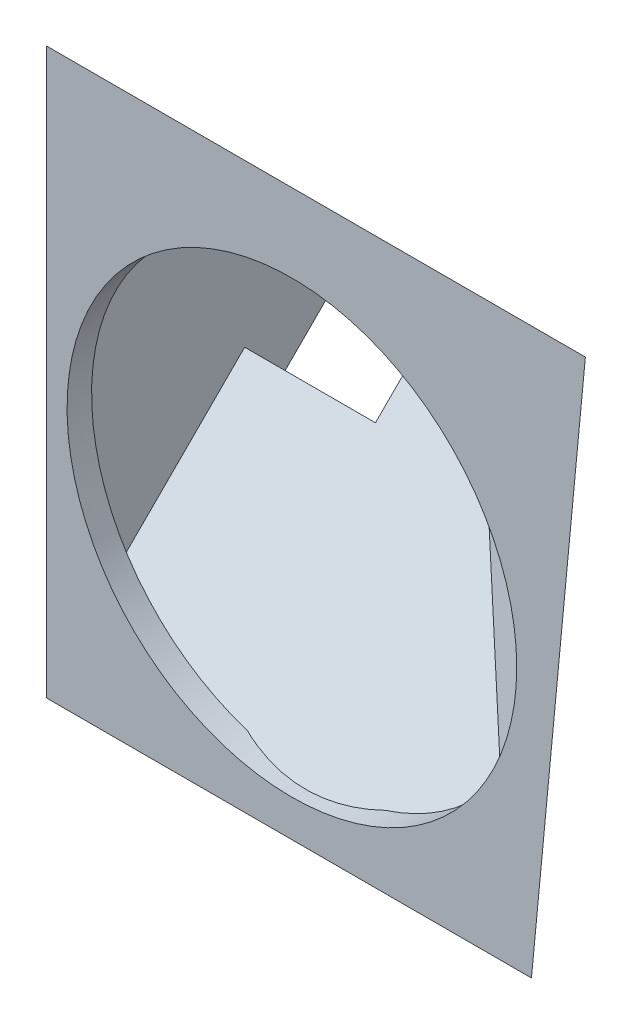
from build123d import *

# Parameters (mm, degrees)
SKETCH1_W            = 60
SKETCH1_H            = 60
SKETCH1_R            = 27.5
BOSS_EXTRUDE2_DEPTH  = 2
BOSS_EXTRUDE3_DEPTH  = 1
BOSS_EXTRUDE4_DEPTH  = 59
BOSS_EXTRUDE5_DEPTH  = 20
SKETCH6_W            = 4
SKETCH6_H            = 14.848240743
CUT_EXTRUDE1_DEPTH   = 20
BOSS_EXTRUDE6_DEPTH  = 2
SKETCH9_W            = 21
SKETCH9_H            = 33.426406871
BOSS_EXTRUDE8_DEPTH  = 2
SKETCH11_W           = 57.719066806
SKETCH11_H           = 59.906444101
BOSS_EXTRUDE9_DEPTH  = 1.5
CUT_EXTRUDE3_DEPTH   = 44.570078861
BOSS_EXTRUDE10_REACH = 41.922
CUT_EXTRUDE4_DEPTH   = 26.5
SKETCH15_W           = 98.795654727
SKETCH15_H           = 69.251879537
CUT_EXTRUDE5_DEPTH   = 59.5
SKETCH16_R           = 67.668555037
CUT_EXTRUDE6_DEPTH   = 1093.5
SKETCH17_R           = 80.414803425
CUT_EXTRUDE7_DEPTH   = 212.5
SKETCH18_W           = 81.243812254
SKETCH18_H           = 75.888975698
SKETCH18_R           = 27.5
BOSS_EXTRUDE12_DEPTH = 3
BOSS_EXTRUDE13_DEPTH = 2
SKETCH20_R           = 82.636183776
CUT_EXTRUDE8_DEPTH   = 100
SKETCH21_R           = 85.046347758
CUT_EXTRUDE9_DEPTH   = 22
SKETCH23_R           = 93.159906211
CUT_EXTRUDE11_DEPTH  = 94
SKETCH24_R           = 86.281354965
CUT_EXTRUDE12_DEPTH  = 48
SKETCH25_R           = 66.198443884
CUT_EXTRUDE13_DEPTH  = 170
BOSS_EXTRUDE14_DEPTH = 2
SKETCH27_W           = 18.5
SKETCH27_H           = 15.5
SKETCH27_W_2         = 16
SKETCH27_H_2         = 12
BOSS_EXTRUDE15_DEPTH = 5


with BuildPart() as part:
    # Sketch1 → Boss-Extrude2 (new body)
    with BuildSketch(Plane.XY):
        with Locations((28, 28)):
            Rectangle(SKETCH1_W, SKETCH1_H)
        with Locations((28, 28)):
            Circle(SKETCH1_R, mode=Mode.SUBTRACT)
    extrude(amount=BOSS_EXTRUDE2_DEPTH)

    # Sketch2 → Boss-Extrude3 (add)
    with BuildSketch(Plane.ZY.offset(2)):
        Polygon((2, 58), (-1.535533906, 61.535533906), (-32.535533906, 30.535533906), (0, -2), (0, 58), align=None)
    extrude(amount=-BOSS_EXTRUDE3_DEPTH)

    # Sketch3 → Boss-Extrude4 (add)
    with BuildSketch(Plane(origin=(-1, 0, 0), x_dir=(0, 0, -1), z_dir=(1, 0, 0))):
        Polygon((0, 58), (2.535533906, 60.535533906), (1.535533906, 61.535533906), (-2, 58), align=None)
    extrude(amount=BOSS_EXTRUDE4_DEPTH)

    # Sketch5 → Boss-Extrude5 (add)
    with BuildSketch(Plane(origin=(-1, 0, 0), x_dir=(0, 0, -1), z_dir=(1, 0, 0))):
        Polygon((2.535533906, 60.535533906), (32.535533906, 30.535533906), (31.121320344, 29.121320344), (1.121320344, 59.121320344), align=None)
    extrude(amount=BOSS_EXTRUDE5_DEPTH)

    # Sketch6 → Cut-Extrude1 (cut)
    with BuildSketch(Plane(origin=(0, 31.535533906, -31.535533906), x_dir=(1, 0, 0), z_dir=(0, 0.707106781, -0.707106781))):
        with Locations((2.5, -8.692828461)):
            Rectangle(SKETCH6_W, SKETCH6_H)
    extrude(amount=-CUT_EXTRUDE1_DEPTH, mode=Mode.SUBTRACT)

    # Sketch7 → Boss-Extrude6 (add)
    with BuildSketch(Plane(origin=(0, 31.535533906, -31.535533906), x_dir=(1, 0, 0), z_dir=(0, 0.707106781, -0.707106781))):
        Polygon((19, 1.414213562), (58, -41.012193309), (19, -41.012193309), align=None)
    extrude(amount=-BOSS_EXTRUDE6_DEPTH)

    # Sketch9 → Boss-Extrude8 (add)
    with BuildSketch(Plane(origin=(0, -1, -1), x_dir=(-1, 0, 0), z_dir=(0, -0.707106781, -0.707106781))):
        with Locations((-8.5, 13.884776311)):
            Rectangle(SKETCH9_W, SKETCH9_H)
    extrude(amount=-BOSS_EXTRUDE8_DEPTH)

    # Sketch11 → Boss-Extrude9 (add)
    with BuildSketch(Plane(origin=(22.469349188, -2.1452201, -27.064933845), x_dir=(-0.676752968, -0.520579206, -0.520579206), z_dir=(0.637576713, -0.060871473, -0.767978254))):
        with Locations((-40.536850198, 1.112103584)):
            Rectangle(SKETCH11_W, SKETCH11_H)
    extrude(amount=-BOSS_EXTRUDE9_DEPTH)

    # Sketch12 → Cut-Extrude3 (cut, through all)
    with BuildSketch(Plane(origin=(21.512984119, -2.053912891, -25.912966464), x_dir=(0.770386874, 0.050377589, 0.635583325), z_dir=(-0.637576713, 0.060871473, 0.767978254))):
        Polygon((43.649580839, -2.15177531), (42.724580914, -9.59239755), (74.742668884, 7.823146391), (47.317707346, 58.243324712), align=None)
    extrude(amount=-CUT_EXTRUDE3_DEPTH, mode=Mode.SUBTRACT)

    # Boss-Extrude10: up to this face of the body (flat: up to its plane)
    boss_extrude10_end = Plane(part.part.faces().sort_by_distance((41.682824106, 19.529388287, -10.878669739))[0])
    # Sketch13 → Boss-Extrude10 (add, up to the picked face)
    with BuildSketch(Plane(origin=(19, 0, 0), x_dir=(0, 0, -1), z_dir=(1, 0, 0)), mode=Mode.PRIVATE) as boss_extrude10_sk1:
        Polygon((21.221825407, 22.050252532), (22.636038969, 20.636038969), (-1, -3), (-2.414213562, -1.585786438), align=None)
    boss_extrude10_tool1 = split(extrude(boss_extrude10_sk1.sketch, amount=BOSS_EXTRUDE10_REACH, mode=Mode.PRIVATE), bisect_by=boss_extrude10_end, keep=Keep.BOTH, mode=Mode.PRIVATE)
    add(boss_extrude10_tool1.solids().sort_by_distance((19, 9.525126, -10.110913))[0])

    # Sketch14 → Cut-Extrude4 (cut)
    with BuildSketch(Plane(origin=(21.512984119, -2.053912891, -25.912966464), x_dir=(0.770386874, 0.050377589, 0.635583325), z_dir=(-0.637576713, 0.060871473, 0.767978254))):
        Polygon((41.962116988, -3.069634642), (7.93553086, 22.360087902), (-27.775626078, 49.048772133), (11.868884468, -40.106499749), (63.912471384, -11.732484985), align=None)
    extrude(amount=-CUT_EXTRUDE4_DEPTH, mode=Mode.SUBTRACT)

    # Sketch15 → Cut-Extrude5 (cut)
    with BuildSketch(Plane(origin=(0, -1, -1), x_dir=(-1, 0, 0), z_dir=(0, -0.707106781, -0.707106781))):
        with Locations((-41.379570233, 23.483837132)):
            Rectangle(SKETCH15_W, SKETCH15_H)
    extrude(amount=CUT_EXTRUDE5_DEPTH, mode=Mode.SUBTRACT)

    # Sketch16 → Cut-Extrude6 (cut)
    with BuildSketch(Plane(origin=(22.469349188, -2.1452201, -27.064933845), x_dir=(-0.770386874, -0.050377589, -0.635583325), z_dir=(0.637576713, -0.060871473, -0.767978254))):
        with Locations((-31.476014369, 28.909090329)):
            Circle(SKETCH16_R)
    extrude(amount=CUT_EXTRUDE6_DEPTH, mode=Mode.SUBTRACT)

    # Sketch17 → Cut-Extrude7 (cut)
    with BuildSketch(Plane(origin=(58, 0, 0), x_dir=(0, 0, -1), z_dir=(1, 0, 0))):
        with Locations((-1.230106157, 56.933870915)):
            Circle(SKETCH17_R)
    extrude(amount=CUT_EXTRUDE7_DEPTH, mode=Mode.SUBTRACT)

    # Sketch18 → Boss-Extrude12 (add)
    with BuildSketch(Plane.XY.offset(2)):
        with Locations((28, 28)):
            Rectangle(SKETCH18_W, SKETCH18_H)
        with Locations((28, 28)):
            Circle(SKETCH18_R, mode=Mode.SUBTRACT)
    extrude(amount=-BOSS_EXTRUDE12_DEPTH)

    # Sketch19 → Boss-Extrude13 (add)
    with BuildSketch(Plane(origin=(22.469349188, -2.1452201, -27.064933845), x_dir=(-0.770386874, -0.050377589, -0.635583325), z_dir=(0.637576713, -0.060871473, -0.767978254))):
        Polygon((-48.688581729, 61.770152877), (-46.120529867, 41.112957892), (-46.120529867, 60.372277801), align=None)
        Polygon((-46.120529867, 41.112957892), (-40.895361663, -0.917859332), (4.352561758, 32.898114271), (-46.120529867, 60.372277801), align=None)
    extrude(amount=-BOSS_EXTRUDE13_DEPTH)

    # Sketch20 → Cut-Extrude8 (cut)
    with BuildSketch(Plane(origin=(22.469349188, -2.1452201, -27.064933845), x_dir=(-0.770386874, -0.050377589, -0.635583325), z_dir=(0.637576713, -0.060871473, -0.767978254))):
        with Locations((-26.945010232, 29.388055989)):
            Circle(SKETCH20_R)
    extrude(amount=CUT_EXTRUDE8_DEPTH, mode=Mode.SUBTRACT)

    # Sketch21 → Cut-Extrude9 (cut)
    with BuildSketch(Plane(origin=(0, 31.535533906, -31.535533906), x_dir=(1, 0, 0), z_dir=(0, 0.707106781, -0.707106781))):
        with Locations((19.590538608, -26.723706738)):
            Circle(SKETCH21_R)
    extrude(amount=CUT_EXTRUDE9_DEPTH, mode=Mode.SUBTRACT)

    # Sketch23 → Cut-Extrude11 (cut)
    with BuildSketch(Plane.ZY.offset(2)):
        with Locations((-13.361611356, 29.287919071)):
            Circle(SKETCH23_R)
    extrude(amount=CUT_EXTRUDE11_DEPTH, mode=Mode.SUBTRACT)

    # Sketch24 → Cut-Extrude12 (cut)
    with BuildSketch(Plane(origin=(0, -1, -1), x_dir=(-1, 0, 0), z_dir=(0, -0.707106781, -0.707106781))):
        with Locations((-12.739775939, 17.868647739)):
            Circle(SKETCH24_R)
    extrude(amount=CUT_EXTRUDE12_DEPTH, mode=Mode.SUBTRACT)

    # Sketch25 → Cut-Extrude13 (cut)
    with BuildSketch(Plane.XY.offset(2)):
        with Locations((30.355803371, 29.212907652)):
            Circle(SKETCH25_R)
    extrude(amount=CUT_EXTRUDE13_DEPTH, mode=Mode.SUBTRACT)

    # Sketch26 → Boss-Extrude14 (add)
    with BuildSketch(Plane(origin=(0, -1, -1), x_dir=(-1, 0, 0), z_dir=(0, -0.707106781, -0.707106781))):
        Polygon((-15, 30.597979746), (-15, 44.597979746), (-18.325381464, 44.597979746), (-30.150830661, 29.463089368), (-15, 29.463089368), align=None)
    extrude(amount=-BOSS_EXTRUDE14_DEPTH)

    # Sketch27 → Boss-Extrude15 (add)
    with BuildSketch(Plane(origin=(0, -1, -1), x_dir=(-1, 0, 0), z_dir=(0, -0.707106781, -0.707106781))):
        with Locations((-7.25, 36.847979746)):
            Rectangle(SKETCH27_W, SKETCH27_H)
        with Locations((-7, 36.597979746)):
            Rectangle(SKETCH27_W_2, SKETCH27_H_2, mode=Mode.SUBTRACT)
    extrude(amount=BOSS_EXTRUDE15_DEPTH)


solid = part.part
